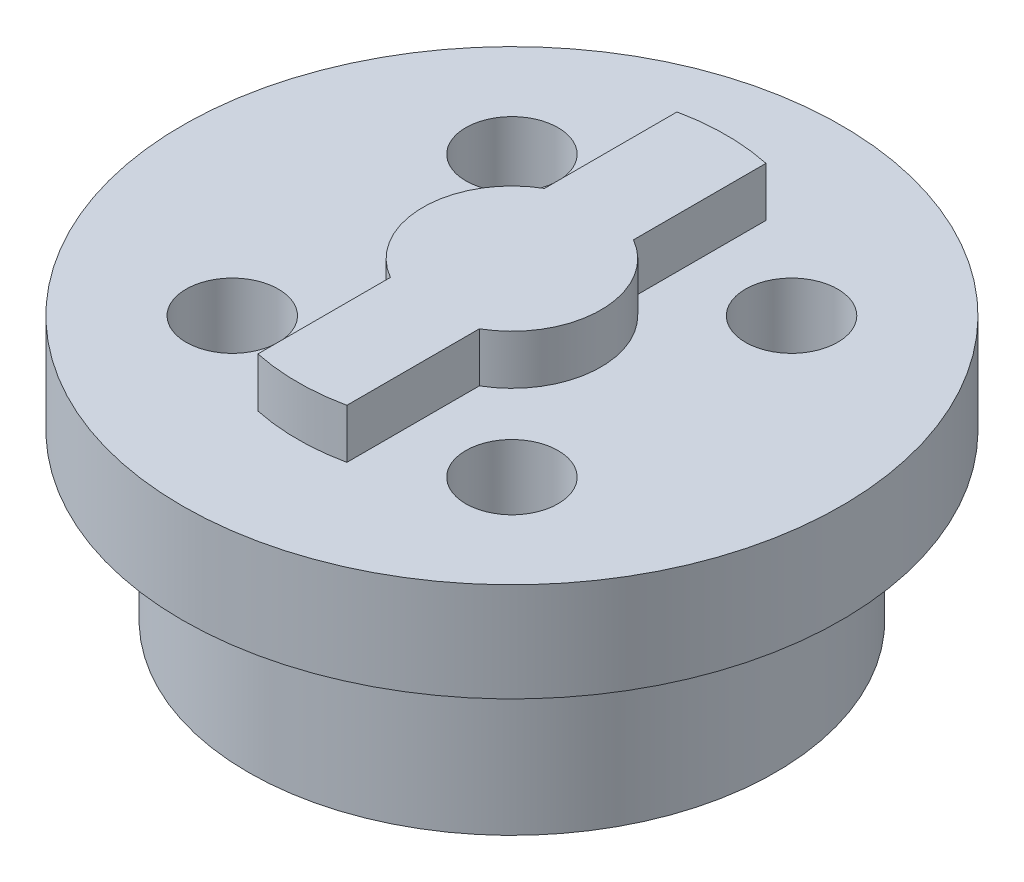
from build123d import *

# Parameters (mm, degrees)
SKETCH1_R           = 10
BOSS_EXTRUDE1_DEPTH = 8
BOSS_EXTRUDE2_DEPTH = 1.5
SKETCH5_R           = 10
SKETCH5_R_2         = 8
CUT_EXTRUDE1_DEPTH  = 5
SKETCH6_R           = 1.4
CUT_EXTRUDE2_DEPTH  = 8
CIRPATTERN1_COUNT   = 4


with BuildPart() as part:
    # Sketch1 → Boss-Extrude1 (new body)
    with BuildSketch(Plane(origin=(0, 0, 0), x_dir=(1, 0, 0), z_dir=(0, 1, 0))):
        Circle(SKETCH1_R)
    extrude(amount=BOSS_EXTRUDE1_DEPTH)

    # Sketch4 → Boss-Extrude2 (add)
    with BuildSketch(Plane(origin=(0, 8, 0), x_dir=(1, 0, 0), z_dir=(0, 1, 0))):
        with BuildLine():
            Line((-1.35, 6.358262341), (-1.35, 2.33826859))
            ThreePointArc((-1.35, 2.33826859), (-2.7, 0), (-1.35, -2.33826859))
            Line((-1.35, -2.33826859), (-1.35, -6.358262341))
            ThreePointArc((-1.35, -6.358262341), (0, -6.5), (1.35, -6.358262341))
            Line((1.35, -6.358262341), (1.35, -2.33826859))
            ThreePointArc((1.35, -2.33826859), (2.7, 0), (1.35, 2.33826859))
            Line((1.35, 2.33826859), (1.35, 6.358262341))
            ThreePointArc((1.35, 6.358262341), (0, 6.5), (-1.35, 6.358262341))
        make_face()
    extrude(amount=BOSS_EXTRUDE2_DEPTH)

    # Sketch5 → Cut-Extrude1 (cut)
    with BuildSketch(Plane(origin=(0, 0, 0), x_dir=(1, 0, 0), z_dir=(0, 1, 0))):
        Circle(SKETCH5_R)
        Circle(SKETCH5_R_2, mode=Mode.SUBTRACT)
    extrude(amount=CUT_EXTRUDE1_DEPTH, mode=Mode.SUBTRACT)

    # Sketch6 → Cut-Extrude2 (cut)
    with BuildSketch(Plane.XZ):
        with Locations((4.242640687, 4.242640687)):
            Circle(SKETCH6_R)
    cut_extrude2 = extrude(amount=-CUT_EXTRUDE2_DEPTH, mode=Mode.SUBTRACT)

    # CirPattern1: Cut-Extrude2 ×4 about axis
    cirpattern1_axis = Axis((0, 0, 0), (0, 1, 0))
    for i in range(1, CIRPATTERN1_COUNT):
        add(cut_extrude2.rotate(cirpattern1_axis, i * 360 / CIRPATTERN1_COUNT), mode=Mode.SUBTRACT)


solid = part.part
